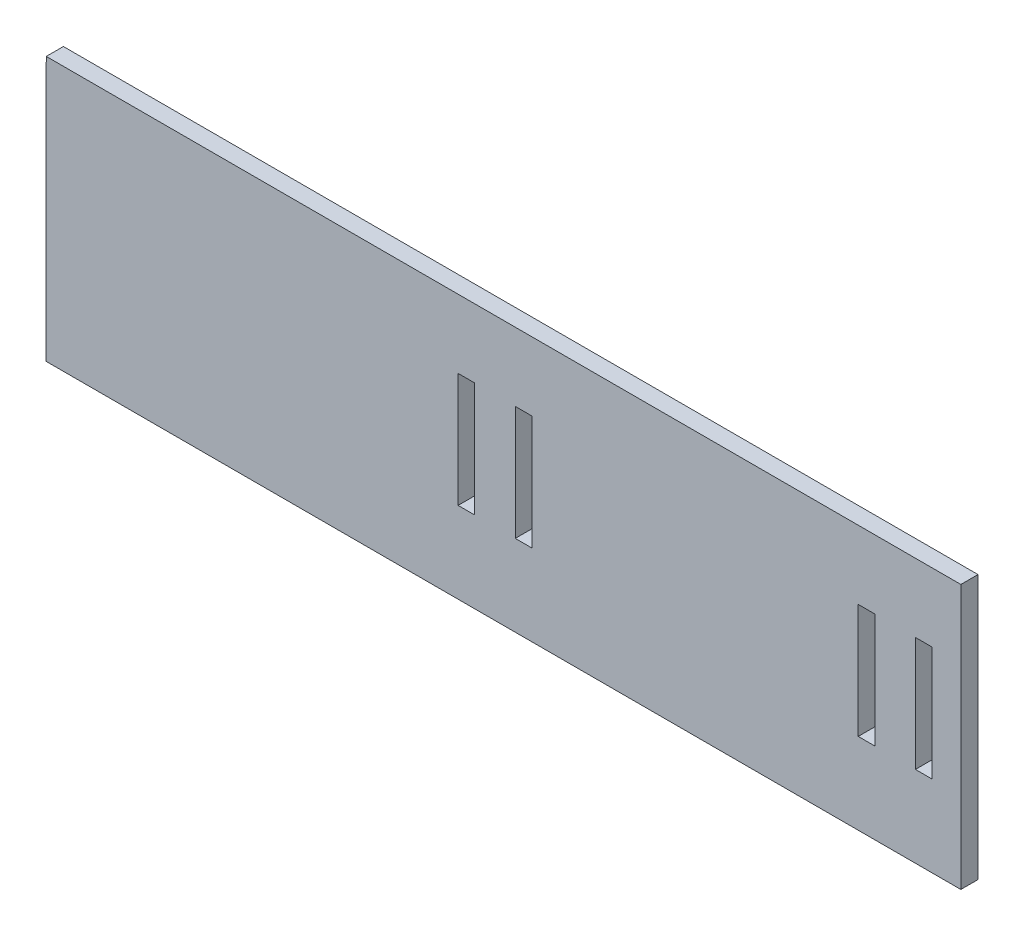
from build123d import *

# Parameters (mm, degrees)
BOSS_EXTRUDE1_DEPTH = 3
SKETCH4_W           = 2.9
SKETCH4_H           = 20
CUT_EXTRUDE1_DEPTH  = 4


with BuildPart() as part:
    # Sketch3 → Boss-Extrude1 (new body)
    with BuildSketch(Plane(origin=(0, 0, 0), x_dir=(0.999999536, -0.000963417, 0), z_dir=(0, 0, 1))):
        Polygon((87.907726379, 95.819824151), (-72.092273621, 95.665677408), (-72.092273621, 49.448943998), (87.95225233, 49.603133638), align=None)
    extrude(amount=BOSS_EXTRUDE1_DEPTH)

    # Sketch4 → Cut-Extrude1 (cut, through all)
    with BuildSketch(Plane.XY.offset(3)):
        with Locations((1.5, 73.735087911)):
            Rectangle(SKETCH4_W, SKETCH4_H)
        with Locations((11.5, 73.735087911)):
            Rectangle(SKETCH4_W, SKETCH4_H)
        with Locations((71.5, 73.735087911)):
            Rectangle(SKETCH4_W, SKETCH4_H)
        with Locations((81.5, 73.735087911)):
            Rectangle(SKETCH4_W, SKETCH4_H)
    extrude(amount=-CUT_EXTRUDE1_DEPTH, mode=Mode.SUBTRACT)


solid = part.part
